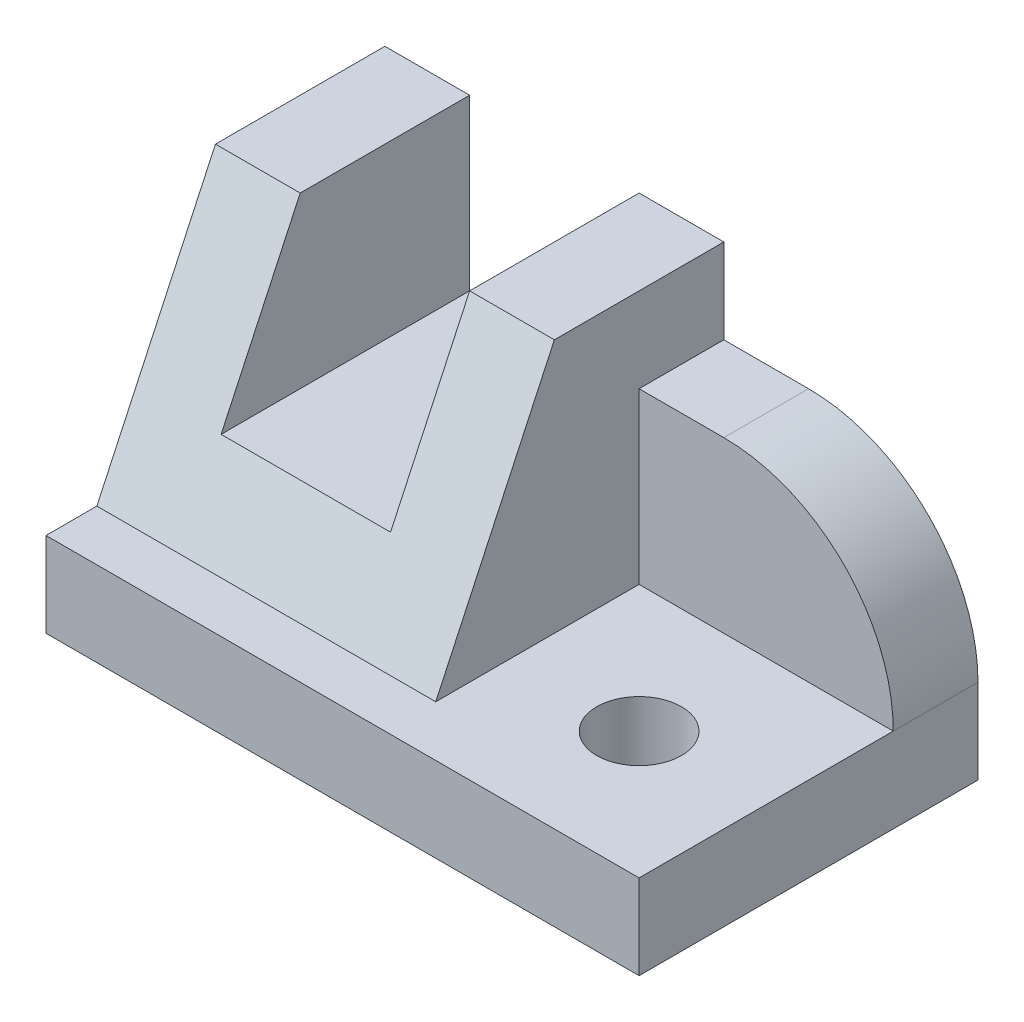
from build123d import *

# Parameters (mm, degrees)
BOSS_EXTRUDE1_DEPTH            = 40
SKETCH2_W                      = 40
SKETCH2_H                      = 30
BOSS_EXTRUDE2_DEPTH            = 20
BOSS_EXTRUDE3_DEPTH            = 30
CUT_EXTRUDE1_DEPTH             = 30
SKETCH5_W                      = 70
SKETCH5_H                      = 40
BOSS_EXTRUDE4_DEPTH            = 10
SKETCH6_W                      = 20
SKETCH6_H                      = 20
CUT_EXTRUDE2_DEPTH             = 41
F_10_0_10_DIAMETER_HOLE1_D     = 10
F_10_0_10_DIAMETER_HOLE1_DEPTH = 40
FILLET1_R                      = 20


with BuildPart() as part:
    # Sketch1 → Boss-Extrude1 (new body)
    with BuildSketch(Plane(origin=(0, 0, 0), x_dir=(0, -1, 0), z_dir=(-1, 0, 0))):
        Polygon((-10, -6), (-40, -20), (-10, -20), align=None)
    extrude(amount=-BOSS_EXTRUDE1_DEPTH)

    # Sketch2 → Boss-Extrude2 (add)
    with BuildSketch(Plane(origin=(0, 0, -20), x_dir=(-1, 0, 0), z_dir=(0, 0, -1))):
        with Locations((-20, 25)):
            Rectangle(SKETCH2_W, SKETCH2_H)
    extrude(amount=BOSS_EXTRUDE2_DEPTH)

    # Sketch3 → Boss-Extrude3 (add)
    with BuildSketch(Plane(origin=(40, 0, 0), x_dir=(0, 0, -1), z_dir=(1, 0, 0))):
        Polygon((40, 10), (0, 10), (20, 40), (40, 40), align=None)
    extrude(amount=BOSS_EXTRUDE3_DEPTH)

    # Sketch4 → Cut-Extrude1 (cut)
    with BuildSketch(Plane(origin=(70, 0, 0), x_dir=(0, 0, -1), z_dir=(1, 0, 0))):
        Polygon((20, 40), (0, 10), (30, 10), (30, 30), (40, 30), (40, 40), align=None)
    extrude(amount=-CUT_EXTRUDE1_DEPTH, mode=Mode.SUBTRACT)

    # Sketch5 → Boss-Extrude4 (add)
    with BuildSketch(Plane.XZ.offset(-10)):
        with Locations((35, -20)):
            Rectangle(SKETCH5_W, SKETCH5_H)
    extrude(amount=BOSS_EXTRUDE4_DEPTH)

    # Sketch6 → Cut-Extrude2 (cut, through all)
    with BuildSketch(Plane(origin=(0, 0, -40), x_dir=(-1, 0, 0), z_dir=(0, 0, -1))):
        with Locations((-20, 30)):
            Rectangle(SKETCH6_W, SKETCH6_H)
    extrude(amount=-CUT_EXTRUDE2_DEPTH, mode=Mode.SUBTRACT)

    # Ø10.0 (10) Diameter Hole1
    with Locations(Plane(origin=(0, 0, 0), x_dir=(-1, 0, 0), z_dir=(0, -1, 0))):
        with Locations((-55, 15)):
            Hole(F_10_0_10_DIAMETER_HOLE1_D / 2, depth=F_10_0_10_DIAMETER_HOLE1_DEPTH)

    # Fillet1
    fillet1_edges = [part.edges().sort_by_distance(p)[0] for p in [
        (70, 30, -35),
    ]]
    fillet(fillet1_edges, radius=FILLET1_R)


solid = part.part
